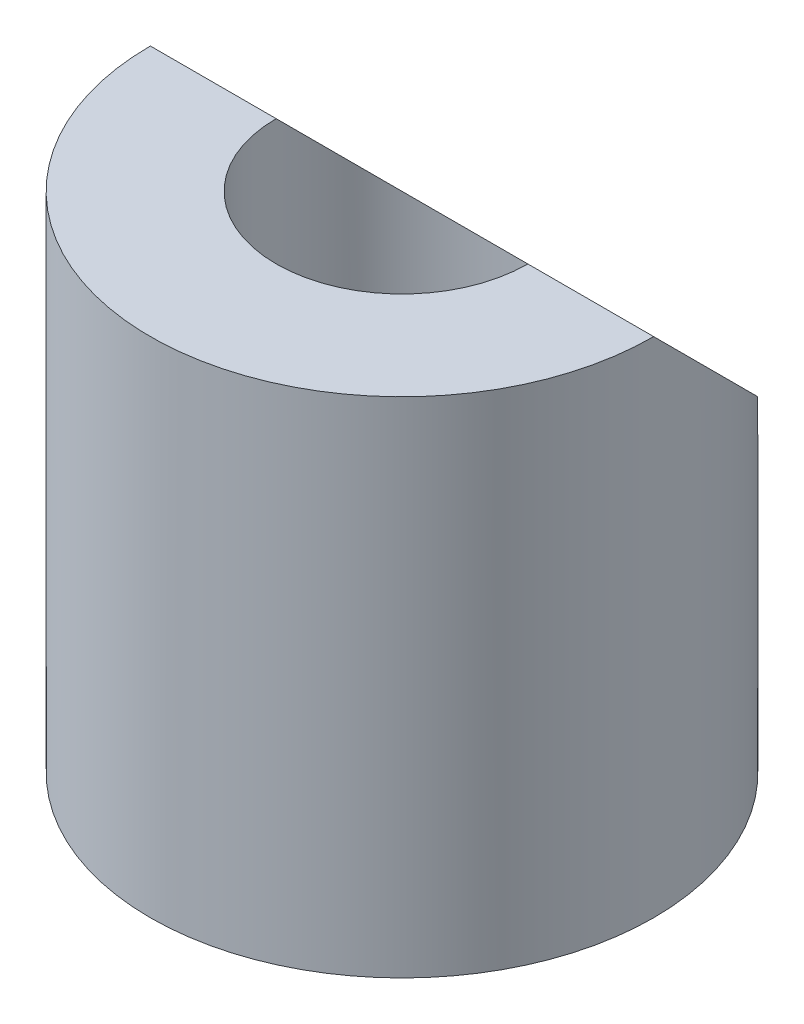
from build123d import *

# Parameters (mm, degrees)
SKETCH1_R           = 2
SKETCH1_R_2         = 1
BOSS_EXTRUDE1_DEPTH = 4
CUT_EXTRUDE1_DEPTH  = 2


with BuildPart() as part:
    # Sketch1 → Boss-Extrude1 (new body)
    with BuildSketch(Plane(origin=(0, 0, 0), x_dir=(1, 0, 0), z_dir=(0, 1, 0))):
        Circle(SKETCH1_R)
        Circle(SKETCH1_R_2, mode=Mode.SUBTRACT)
    extrude(amount=BOSS_EXTRUDE1_DEPTH)

    # Sketch2 → Cut-Extrude1 (cut, symmetric)
    with BuildSketch(Plane(origin=(0, 0, 0), x_dir=(0, 0, -1), z_dir=(1, 0, 0))):
        Polygon((2, 2), (2, 4), (0, 4), align=None)
        Polygon((2, 4), (0, 4), (2, 2), align=None)
    extrude(amount=CUT_EXTRUDE1_DEPTH, both=True, mode=Mode.SUBTRACT)


solid = part.part
